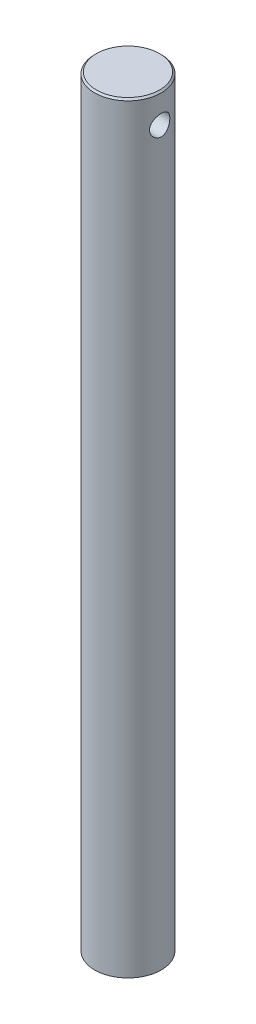
from build123d import *

# Parameters (mm, degrees)
SKETCH1_R           = 10.00125
BOSS_EXTRUDE1_DEPTH = 203.2
SKETCH2_R           = 10.00125
BOSS_EXTRUDE2_DEPTH = 25.7175
SKETCH4_R           = 3.048
CUT_EXTRUDE1_DEPTH  = 25.4
CHAMFER1_SIZE       = 0.508


with BuildPart() as part:
    # Sketch1 → Boss-Extrude1 (new body)
    with BuildSketch(Plane(origin=(0, 0, 0), x_dir=(1, 0, 0), z_dir=(0, 1, 0))):
        Circle(SKETCH1_R)
    extrude(amount=BOSS_EXTRUDE1_DEPTH)

    # Sketch2 → Boss-Extrude2 (add)
    with BuildSketch(Plane(origin=(0, 203.2, 0), x_dir=(1, 0, 0), z_dir=(0, 1, 0))):
        Circle(SKETCH2_R)
    extrude(amount=BOSS_EXTRUDE2_DEPTH)

    # Sketch4 → Cut-Extrude1 (cut)
    with BuildSketch(Plane(origin=(10.00125, 0, 0), x_dir=(0, 0, -1), z_dir=(1, 0, 0))):
        with Locations((0, 220.0275)):
            Circle(SKETCH4_R)
    extrude(amount=-CUT_EXTRUDE1_DEPTH, mode=Mode.SUBTRACT)

    # Chamfer1
    chamfer1_edges = [part.edges().sort_by_distance(p)[0] for p in [
        (-10.00125, 228.9175, 0),
    ]]
    chamfer(chamfer1_edges, length=CHAMFER1_SIZE)


solid = part.part
